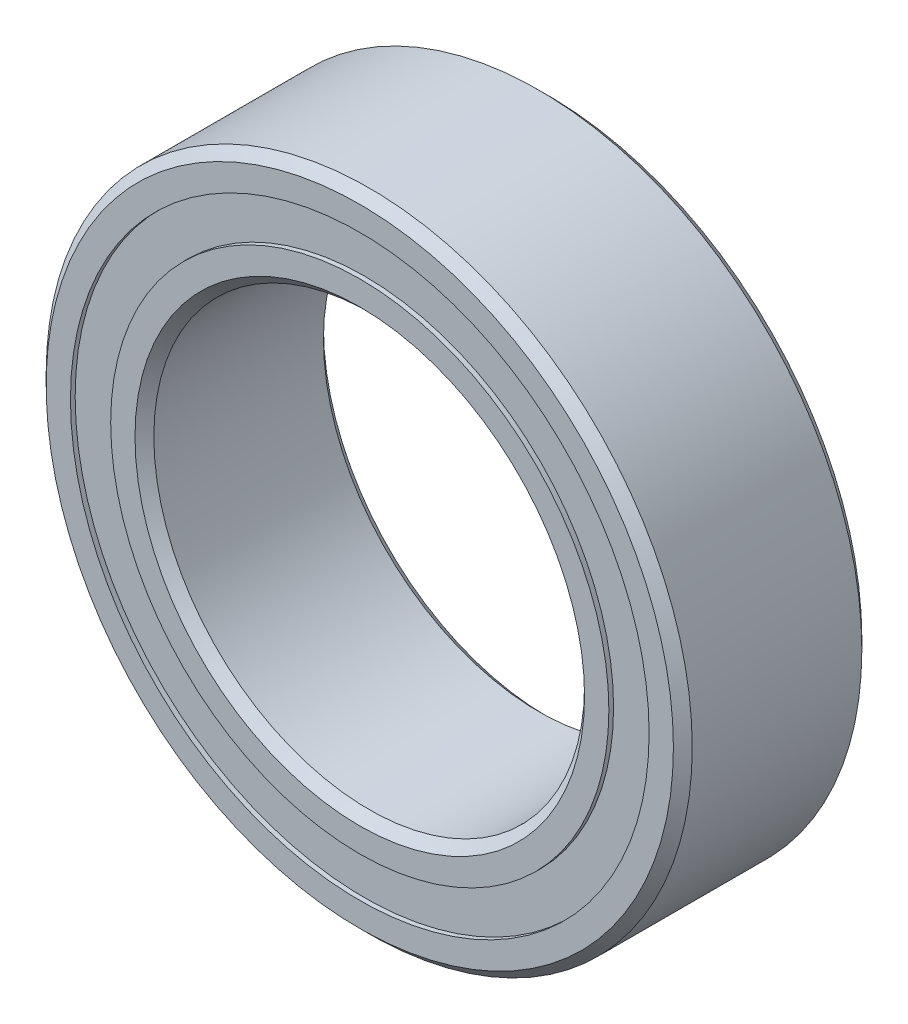
from build123d import *

# Parameters (mm, degrees)
CIRPATTERN1_COUNT = 12
SKETCH5_W         = 0.79963562
SKETCH5_H         = 0.747252748


with BuildPart() as part:
    # Sketch1 → Revolve1 (revolve)
    with BuildSketch(Plane(origin=(0, 0, 0), x_dir=(0, 0, -1), z_dir=(1, 0, 0))):
        with BuildLine():
            Line((1.575, 6), (-1.575, 6))
            Line((-1.575, 6), (-1.75, 5.825))
            Line((-1.75, 5.825), (-1.75, 5.373626374))
            Line((-1.75, 5.373626374), (-0.777777778, 5.373626374))
            ThreePointArc((-0.777777778, 5.373626374), (0, 5.86286438), (0.777777778, 5.373626374))
            Line((0.777777778, 5.373626374), (1.75, 5.373626374))
            Line((1.75, 5.373626374), (1.75, 5.825))
            Line((1.75, 5.825), (1.575, 6))
        make_face()
    revolve(axis=Axis((0, 0, 1.75), (0, 0, -1)))


with BuildPart() as body_2:
    # Sketch3 → Revolve3 (revolve)
    with BuildSketch(Plane(origin=(0, 0, 0), x_dir=(0, 0, -1), z_dir=(1, 0, 0))):
        with BuildLine():
            Line((-1.75, 4.626373626), (-0.777777778, 4.626373626))
            ThreePointArc((-0.777777778, 4.626373626), (0, 4.13713562), (0.777777778, 4.626373626))
            Line((0.777777778, 4.626373626), (1.75, 4.626373626))
            Line((1.75, 4.626373626), (1.75, 4.175))
            Line((1.75, 4.175), (1.575, 4))
            Line((1.575, 4), (-1.575, 4))
            Line((-1.575, 4), (-1.75, 4.175))
            Line((-1.75, 4.175), (-1.75, 4.626373626))
        make_face()
    revolve(axis=Axis((0, 0, 1.75), (0, 0, -1)))


with BuildPart() as body_3:
    # Sketch4 → Revolve4 (revolve)
    with BuildSketch(Plane(origin=(0, 0, 0), x_dir=(0, 0, -1), z_dir=(1, 0, 0))):
        with BuildLine():
            Line((-0.86286438, 5), (0.86286438, 5))
            ThreePointArc((0.86286438, 5), (0, 5.86286438), (-0.86286438, 5))
        make_face()
    revolve(axis=Axis((0, 5, 0.86286438), (0, 0, -1)))


with BuildPart() as cirpattern1_1:
    # CirPattern1: pattern copy
    add(body_3.part.rotate(Axis((0, 0, 0), (0, 0, 1)), 1 * 360 / CIRPATTERN1_COUNT))


with BuildPart() as cirpattern1_2:
    # CirPattern1: pattern copy
    add(body_3.part.rotate(Axis((0, 0, 0), (0, 0, 1)), 2 * 360 / CIRPATTERN1_COUNT))


with BuildPart() as cirpattern1_3:
    # CirPattern1: pattern copy
    add(body_3.part.rotate(Axis((0, 0, 0), (0, 0, 1)), 3 * 360 / CIRPATTERN1_COUNT))


with BuildPart() as cirpattern1_4:
    # CirPattern1: pattern copy
    add(body_3.part.rotate(Axis((0, 0, 0), (0, 0, 1)), 4 * 360 / CIRPATTERN1_COUNT))


with BuildPart() as cirpattern1_5:
    # CirPattern1: pattern copy
    add(body_3.part.rotate(Axis((0, 0, 0), (0, 0, 1)), 5 * 360 / CIRPATTERN1_COUNT))


with BuildPart() as cirpattern1_6:
    # CirPattern1: pattern copy
    add(body_3.part.rotate(Axis((0, 0, 0), (0, 0, 1)), 6 * 360 / CIRPATTERN1_COUNT))


with BuildPart() as cirpattern1_7:
    # CirPattern1: pattern copy
    add(body_3.part.rotate(Axis((0, 0, 0), (0, 0, 1)), 7 * 360 / CIRPATTERN1_COUNT))


with BuildPart() as cirpattern1_8:
    # CirPattern1: pattern copy
    add(body_3.part.rotate(Axis((0, 0, 0), (0, 0, 1)), 8 * 360 / CIRPATTERN1_COUNT))


with BuildPart() as cirpattern1_9:
    # CirPattern1: pattern copy
    add(body_3.part.rotate(Axis((0, 0, 0), (0, 0, 1)), 9 * 360 / CIRPATTERN1_COUNT))


with BuildPart() as cirpattern1_10:
    # CirPattern1: pattern copy
    add(body_3.part.rotate(Axis((0, 0, 0), (0, 0, 1)), 10 * 360 / CIRPATTERN1_COUNT))


with BuildPart() as cirpattern1_11:
    # CirPattern1: pattern copy
    add(body_3.part.rotate(Axis((0, 0, 0), (0, 0, 1)), 11 * 360 / CIRPATTERN1_COUNT))


with BuildPart() as body_15:
    # Sketch5 → Revolve5 (revolve)
    with BuildSketch(Plane(origin=(0, 0, 0), x_dir=(0, 0, -1), z_dir=(1, 0, 0))):
        with Locations((-1.26268219, 5)):
            Rectangle(SKETCH5_W, SKETCH5_H)
        with Locations((1.26268219, 5)):
            Rectangle(SKETCH5_W, SKETCH5_H)
    revolve(axis=Axis((0, 0, 1.75), (0, 0, -1)))


solid = Compound([part.part, body_2.part, body_3.part, cirpattern1_1.part, cirpattern1_2.part, cirpattern1_3.part, cirpattern1_4.part, cirpattern1_5.part, cirpattern1_6.part, cirpattern1_7.part, cirpattern1_8.part, cirpattern1_9.part, cirpattern1_10.part, cirpattern1_11.part, body_15.part])
